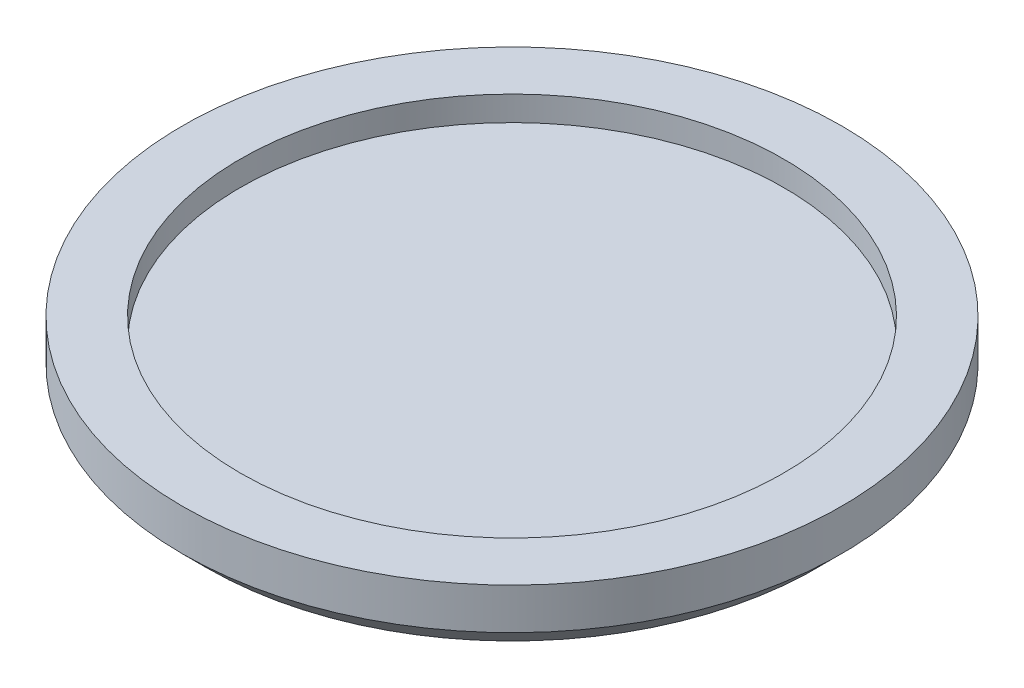
from build123d import *

# Parameters (mm, degrees)
SKETCH1_R           = 20
BOSS_EXTRUDE1_DEPTH = 4
SKETCH2_R           = 16.5
CUT_EXTRUDE1_DEPTH  = 1.5
CHAMFER1_SIZE       = 1.5


with BuildPart() as part:
    # Sketch1 → Boss-Extrude1 (new body)
    with BuildSketch(Plane(origin=(0, 0, 0), x_dir=(1, 0, 0), z_dir=(0, 1, 0))):
        Circle(SKETCH1_R)
    extrude(amount=BOSS_EXTRUDE1_DEPTH)

    # Sketch2 → Cut-Extrude1 (cut)
    with BuildSketch(Plane(origin=(0, 4, 0), x_dir=(1, 0, 0), z_dir=(0, 1, 0))):
        Circle(SKETCH2_R)
    extrude(amount=-CUT_EXTRUDE1_DEPTH, mode=Mode.SUBTRACT)

    # Chamfer1
    chamfer1_edges = [part.edges().sort_by_distance(p)[0] for p in [
        (-20, 0, 0),
    ]]
    chamfer(chamfer1_edges, length=CHAMFER1_SIZE)


solid = part.part
